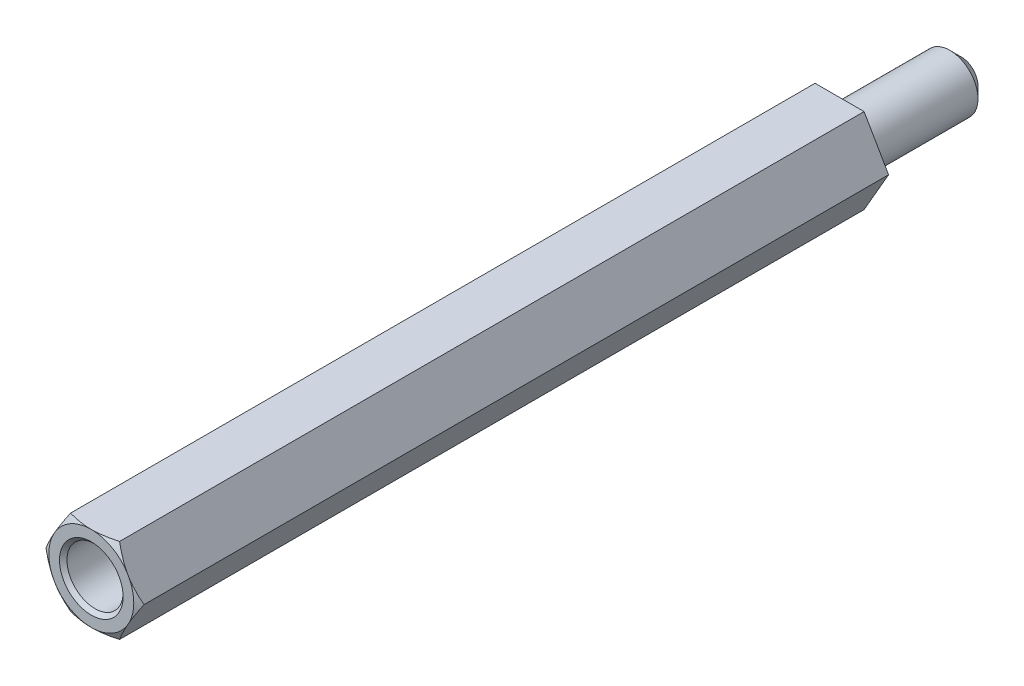
from build123d import *

# Parameters (mm, degrees)
BOSS_EXTRUDE1_DEPTH     = 40
SKETCH2_R               = 1.5
CUT_EXTRUDE1_DEPTH      = 1
CUT_EXTRUDE1_DEPTH_BACK = 12
CHAMFER1_SIZE           = 0.2
SKETCH4_R               = 1.5
BOSS_EXTRUDE2_DEPTH     = 6.5
CHAMFER2_SIZE           = 0.6


with BuildPart() as part:
    # Sketch1 → Boss-Extrude1 (new body)
    with BuildSketch(Plane.XY):
        Polygon((2.621170222, 0), (1.310585111, 2.27), (-1.310585111, 2.27), (-2.621170222, 0), (-1.310585111, -2.27), (1.310585111, -2.27), align=None)
    extrude(amount=BOSS_EXTRUDE1_DEPTH)

    # Sketch2 → Cut-Extrude1 (cut, two sides)
    with BuildSketch(Plane.XY.offset(40)) as cut_extrude1_sk:
        Circle(SKETCH2_R)
    extrude(amount=CUT_EXTRUDE1_DEPTH, mode=Mode.SUBTRACT)
    extrude(cut_extrude1_sk.sketch, amount=-CUT_EXTRUDE1_DEPTH_BACK, mode=Mode.SUBTRACT)

    # Sketch3 → Cut-Revolve1 (revolve, cut)
    with BuildSketch(Plane(origin=(0, 0, 0), x_dir=(1, 0, 0), z_dir=(0, 1, 0))):
        Polygon((-2.621170222, -40), (-2.271170222, -40), (-2.621170222, -39.8), align=None)
    revolve(axis=Axis((0, 0, 28), (0, 0, 1)), mode=Mode.SUBTRACT)

    # Chamfer1
    chamfer1_edges = [part.edges().sort_by_distance(p)[0] for p in [
        (-1.5, 0, 40),
    ]]
    chamfer(chamfer1_edges, length=CHAMFER1_SIZE)

    # Sketch4 → Boss-Extrude2 (add)
    with BuildSketch(Plane(origin=(0, 0, 0), x_dir=(-1, 0, 0), z_dir=(0, 0, -1))):
        Circle(SKETCH4_R)
    extrude(amount=BOSS_EXTRUDE2_DEPTH)

    # Chamfer2
    chamfer2_edges = [part.edges().sort_by_distance(p)[0] for p in [
        (1.5, 0, -6.5),
    ]]
    chamfer(chamfer2_edges, length=CHAMFER2_SIZE)


solid = part.part
